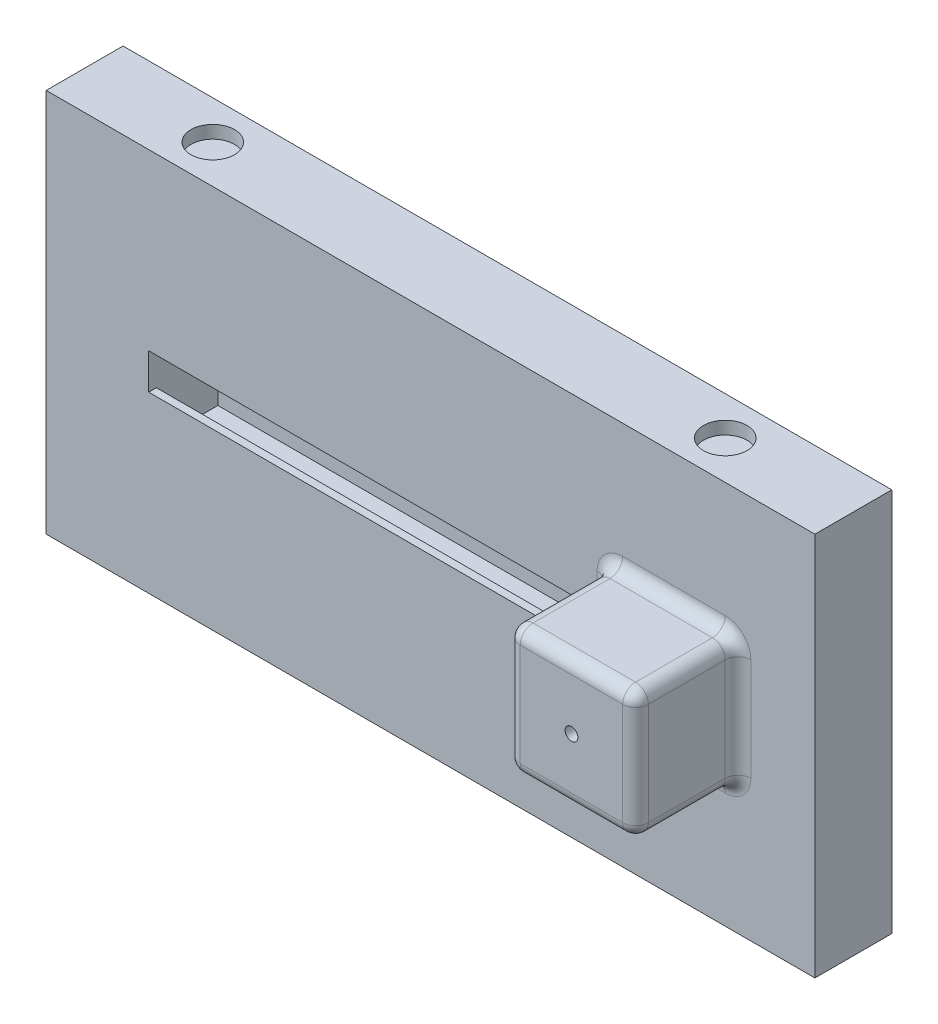
from build123d import *

# Parameters (mm, degrees)
SKETCH1_W               = 300
SKETCH1_H               = 150
SKETCH1_W_2             = 220
SKETCH1_H_2             = 50
BOSS_EXTRUDE2_DEPTH     = 15
SKETCH2_W               = 220
SKETCH2_H               = 18
BOSS_EXTRUDE3_DEPTH     = 3
MIRROR2_COPY_1_SKETCH_W = 220
MIRROR2_COPY_1_SKETCH_H = 18
MIRROR2_COPY_1_DEPTH    = 3
SKETCH3_W               = 220
SKETCH3_H               = 14
BOSS_EXTRUDE4_DEPTH     = 2
SKETCH5_R               = 8.5
CUT_EXTRUDE2_DEPTH      = 5
SKETCH6_W               = 50
SKETCH6_H               = 50
SKETCH6_R               = 2.5
BOSS_EXTRUDE5_DEPTH     = 40
FILLET3_R               = 5


with BuildPart() as part:
    # Sketch1 → Boss-Extrude2 (new body, symmetric)
    with BuildSketch(Plane.XY):
        Rectangle(SKETCH1_W, SKETCH1_H)
        Rectangle(SKETCH1_W_2, SKETCH1_H_2, mode=Mode.SUBTRACT)
    extrude(amount=BOSS_EXTRUDE2_DEPTH, both=True)

    # Sketch2 → Boss-Extrude3 (add)
    with BuildSketch(Plane.XY.offset(15)):
        with Locations((0, 16)):
            Rectangle(SKETCH2_W, SKETCH2_H)
    boss_extrude3 = extrude(amount=-BOSS_EXTRUDE3_DEPTH)

    # Mirror1: Boss-Extrude3 across plane
    add(boss_extrude3.mirror(Plane.XY))

    # Mirror2: Boss-Extrude3 across plane
    add(boss_extrude3.mirror(Plane.ZX))

    # Mirror2 copy 1 sketch → Mirror2 copy 1 (add)
    with BuildSketch(Plane(origin=(0, 0, -15), x_dir=(1, 0, 0), z_dir=(0, 0, -1))):
        with Locations((0, 16)):
            Rectangle(MIRROR2_COPY_1_SKETCH_W, MIRROR2_COPY_1_SKETCH_H)
    extrude(amount=-MIRROR2_COPY_1_DEPTH)

    # Sketch3 → Boss-Extrude4 (add)
    with BuildSketch(Plane(origin=(0, 0, -15), x_dir=(-1, 0, 0), z_dir=(0, 0, -1))):
        Rectangle(SKETCH3_W, SKETCH3_H)
    extrude(amount=-BOSS_EXTRUDE4_DEPTH)

    # Sketch5 → Cut-Extrude2 (cut)
    with BuildSketch(Plane(origin=(0, 75, 0), x_dir=(1, 0, 0), z_dir=(0, 1, 0))):
        with Locations((-100, 0)):
            Circle(SKETCH5_R)
        with Locations((100, 0)):
            Circle(SKETCH5_R)
    cut_extrude2 = extrude(amount=-CUT_EXTRUDE2_DEPTH, mode=Mode.SUBTRACT)

    # Mirror3: Cut-Extrude2 across plane
    add(cut_extrude2.mirror(Plane.ZX), mode=Mode.SUBTRACT)

    # Sketch6 → Boss-Extrude5 (add)
    with BuildSketch(Plane.XY.offset(15)):
        with Locations((95, 0)):
            Rectangle(SKETCH6_W, SKETCH6_H)
        with Locations((95, 0)):
            Circle(SKETCH6_R, mode=Mode.SUBTRACT)
    extrude(amount=BOSS_EXTRUDE5_DEPTH)

    # Fillet3
    fillet3_edges = [part.edges().sort_by_distance(p)[0] for p in [
        (70, -16, 15),
        (120, 0, 55),
        (95, 25, 55),
        (70, 0, 55),
        (95, -25, 55),
        (120, 0, 15),
        (120, -25, 35),
        (95, 25, 15),
        (120, 25, 35),
        (70, 16, 15),
        (70, 25, 35),
        (95, -25, 15),
        (70, -25, 35),
    ]]
    fillet(fillet3_edges, radius=FILLET3_R)


solid = part.part
